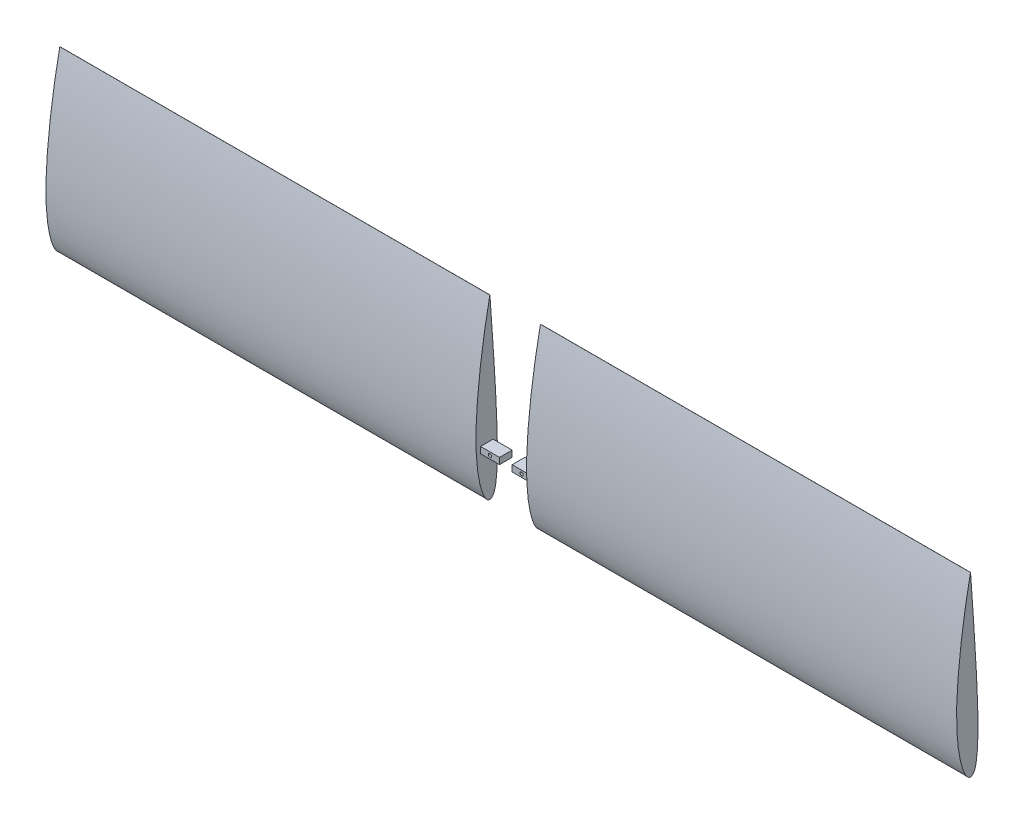
from build123d import *

# Parameters (mm, degrees)
BOSS_EXTRUDE1_DEPTH     = 914.4
SKETCH2_W               = 101.6
SKETCH2_H               = 355.7016
CUT_EXTRUDE1_DEPTH      = 982.547981928
CUT_EXTRUDE1_DEPTH_BACK = 982.547981928
CUT_EXTRUDE3_DEPTH      = 862.965
BOSS_EXTRUDE2_DEPTH     = 862.965
SKETCH7_W               = 25.4
SKETCH7_H               = 12.7
BOSS_EXTRUDE3_DEPTH     = 38.1
SKETCH8_R               = 3.175
CUT_EXTRUDE4_DEPTH      = 982.730874327


with BuildPart() as part:
    # Sketch1 → Boss-Extrude1 (new body)
    with BuildSketch(Plane(origin=(0, 0, 0), x_dir=(0, 0, -1), z_dir=(1, 0, 0))):
        with BuildLine():
            Line((0.107161403, 355.7016), (-0.070689384, 355.7016))
            add(Edge.make_bspline(
                [(-0.070689384, 355.7016), (-0.466477301, 353.821005474), (-1.257390268, 350.062966049), (-2.391261843, 344.419849121), (-3.495815308, 338.780602167), (-4.571931897, 333.145611843), (-5.624146346, 327.516510889), (-6.654132743, 321.894595016), (-7.997398438, 314.419324109), (-9.945522406, 303.25746297), (-12.095688112, 290.277775074), (-14.108266379, 277.369668), (-15.729652448, 266.404083363), (-17.745206313, 251.980108498), (-19.571200264, 237.689627436), (-21.215305741, 223.549431816), (-22.347366905, 213.141900318), (-23.38648148, 202.878012782), (-24.331674295, 192.768060411), (-25.180326784, 182.822187649), (-25.928484577, 173.050367055), (-26.674562593, 161.923020833), (-27.345486328, 149.535714938), (-27.840551721, 135.990974586), (-28.060725611, 122.943312688), (-28.002046095, 110.422427171), (-27.702820577, 99.702001348), (-27.264430386, 90.695171909), (-26.778207129, 83.305058943), (-26.183602895, 76.189184622), (-25.486294476, 69.354718788), (-24.692398131, 62.80853729), (-23.808328586, 56.557201024), (-22.840687769, 50.606973205), (-21.796246166, 44.963830369), (-20.681960011, 39.633415294), (-19.686877519, 35.395642593), (-18.668840846, 31.420703372), (-17.830503911, 28.402995737), (-16.953038009, 25.502253789), (-16.295688834, 23.446152208), (-15.629016033, 21.473655539), (-14.953909817, 19.585256686), (-14.271253624, 17.781420944), (-13.581895135, 16.062595446), (-12.886661884, 14.429199329), (-12.186346807, 12.881628381), (-11.481686051, 11.420261165), (-10.773396292, 10.04543679), (-10.062097884, 8.757490369), (-9.34839284, 7.556709508), (-8.632792002, 6.443369974), (-7.91573903, 5.417716148), (-7.197605959, 4.479967069), (-6.47867767, 3.630320834), (-5.759155979, 2.868957272), (-5.039142048, 2.19605649), (-4.318657554, 1.611798732), (-3.597634906, 1.11641082), (-2.875952573, 0.710164516), (-2.153489626, 0.393485727), (-1.430202503, 0.166619572), (-0.706187065, 0.03077979), (-0.000985808, -0.015114251), (0.684756584, 0.030079625), (1.348697256, 0.166740712), (2.007659563, 0.393317067), (2.659441583, 0.710058446), (3.302103095, 1.116343264), (3.933909812, 1.611857107), (4.553290425, 2.196297771), (5.158827727, 2.869428129), (5.749231153, 3.631048574), (6.323352434, 4.480969847), (6.880184982, 5.418999484), (7.418887755, 6.444929009), (7.938780897, 7.558528262), (8.439333201, 8.759551829), (8.920187899, 10.047719086), (9.38111076, 11.42273555), (9.822040709, 12.884270251), (10.243003979, 14.431978532), (10.644156378, 16.065484925), (11.025729315, 17.78439363), (11.388030769, 19.588284464), (11.731405451, 21.47671562), (12.056228849, 23.449222111), (12.362904642, 25.505314006), (12.65181215, 27.644482252), (12.923317343, 29.866195243), (13.177757541, 32.169900276), (13.499852463, 35.402342989), (13.858312346, 39.644181211), (14.217474108, 44.973851327), (14.512794252, 50.616200438), (14.744290134, 56.565612117), (14.91180091, 62.816123126), (15.015348807, 69.361468336), (15.055556296, 76.19507344), (15.033927365, 83.310049608), (14.95305361, 90.699222818), (14.816566284, 98.355150745), (14.628926379, 106.27014854), (14.395047132, 114.436264929), (14.119797884, 122.845292004), (13.80742065, 131.488784123), (13.461091997, 140.358056449), (13.082513447, 149.444192088), (12.529118258, 161.966906534), (11.914202813, 174.747012914), (11.23057546, 187.771233814), (10.673385511, 197.800288277), (10.076443223, 207.988276057), (9.333666459, 220.087933402), (8.545388829, 232.345213804), (7.727884289, 244.74825108), (7.012410075, 255.522479057), (6.413248687, 264.566087926), (5.812205548, 273.686981089), (5.209897824, 282.876004642), (4.484082626, 293.955761906), (3.867734567, 303.229482659), (3.360161258, 310.676514812), (2.970245095, 316.279904259), (2.570443063, 321.893186998), (2.160539213, 327.514926735), (1.741925541, 333.143678), (1.317712761, 338.777987211), (0.895533142, 344.416460162), (0.48132907, 350.057405862), (0.231880233, 353.820258158), (0.107161403, 355.7016)],
                knots=[0, 0, 0, 0, 0.007940543, 0.015867786, 0.023782336, 0.031683842, 0.039571466, 0.047443805, 0.055299407, 0.070952907, 0.094259966, 0.109659749, 0.124931368, 0.140060475, 0.169836167, 0.184455938, 0.198878988, 0.213091981, 0.227081364, 0.240833733, 0.254335896, 0.267574898, 0.286913018, 0.305591757, 0.323574751, 0.340828862, 0.357323531, 0.367884026, 0.378086462, 0.387923234, 0.397387015, 0.406470797, 0.41516795, 0.423472244, 0.43137777, 0.438879022, 0.445971139, 0.449362331, 0.455832514, 0.458910652, 0.461883669, 0.464751272, 0.467513247, 0.470169459, 0.472719872, 0.475164567, 0.477503762, 0.479737826, 0.481867333, 0.483893084, 0.485816152, 0.487637951, 0.489360303, 0.49098553, 0.492516542, 0.493957004, 0.495311466, 0.496585561, 0.4977862, 0.498921787, 0.500002352, 0.50103964, 0.502046987, 0.503038995, 0.503951731, 0.504878158, 0.505831393, 0.506823576, 0.507865603, 0.508967032, 0.510136107, 0.511379885, 0.512704371, 0.51411466, 0.515615093, 0.517209348, 0.518900571, 0.520691419, 0.522584144, 0.524580638, 0.526682478, 0.528890964, 0.531207133, 0.533631806, 0.536165599, 0.538808937, 0.541562081, 0.544425147, 0.547398108, 0.550480817, 0.553673027, 0.556974385, 0.563902733, 0.571261381, 0.579045037, 0.58724742, 0.595861595, 0.604880098, 0.614294871, 0.624097261, 0.634278056, 0.644827522, 0.655735355, 0.666990799, 0.678582536, 0.690498843, 0.702727789, 0.715257042, 0.728074047, 0.754520377, 0.768123571, 0.781962351, 0.796022904, 0.810291085, 0.832050541, 0.846772874, 0.861649926, 0.876666219, 0.884221743, 0.899417941, 0.914715475, 0.9300999, 0.937820202, 0.945556969, 0.953308312, 0.961072259, 0.968846879, 0.976629764, 0.984418334, 0.992209516, 1, 1, 1, 1], degree=3))
        make_face()
    extrude(amount=-BOSS_EXTRUDE1_DEPTH)

    # Sketch2 → Cut-Extrude1 (cut, two sides)
    with BuildSketch(Plane.XY) as cut_extrude1_sk:
        with Locations((0, 177.8508)):
            Rectangle(SKETCH2_W, SKETCH2_H)
    extrude(amount=CUT_EXTRUDE1_DEPTH, mode=Mode.SUBTRACT)
    extrude(cut_extrude1_sk.sketch, amount=-CUT_EXTRUDE1_DEPTH_BACK, mode=Mode.SUBTRACT)

    # Sketch4 → Cut-Extrude3 (cut)
    with BuildSketch(Plane(origin=(-50.8, 0, 0), x_dir=(0, 0, -1), z_dir=(1, 0, 0))):
        with BuildLine():
            add(Edge.make_bspline(
                [(0.001596468, 0.634990121), (0.826967902, 0.634990121), (2.460288034, 1.127474544), (4.471748408, 2.891385333), (6.048409656, 5.115682959), (7.725860803, 8.396685666), (9.248617399, 12.803937935), (10.558588728, 18.266080522), (11.537271469, 23.813406951), (12.540599127, 31.267756807), (13.390897577, 40.646027038), (14.019287877, 51.93516664), (14.364838797, 63.240945561), (14.494341209, 74.553940311), (14.440507649, 89.641826641), (14.046896931, 108.502916127), (13.28515646, 131.132642203), (12.358459727, 153.75815723), (11.295867035, 176.377547342), (10.08079803, 198.988797347), (8.25161926, 229.125707637), (6.215879665, 259.254310072), (4.246071484, 289.388584475), (2.759176481, 311.986719647), (1.243059906, 332.911934061), (0.185033848, 346.644175304), (-0.240044354, 352.854074493), (-0.262610008, 353.185684255)],
                knots=[0.503016093, 0.503016093, 0.503016093, 0.503016093, 0.50689878, 0.510781467, 0.514664154, 0.51854684, 0.526312214, 0.534077587, 0.541842961, 0.549608335, 0.565139082, 0.580669829, 0.596200576, 0.611731323, 0.62726207, 0.658323564, 0.689385058, 0.720446552, 0.751508047, 0.782569541, 0.813631035, 0.875754023, 0.906815517, 0.937877012, 0.968938506, 0.993166121, 0.994532897, 0.994532897, 0.994532897, 0.994532897], degree=3))
            add(Edge.make_bspline(
                [(-0.262610008, 353.185684255), (-0.330089775, 352.861585336), (-1.613269803, 346.682459156), (-4.285724244, 332.991692094), (-9.434644884, 304.554879268), (-15.494971488, 266.846612876), (-20.283754942, 228.954525342), (-23.392595569, 198.561830787), (-25.324232267, 175.73139216), (-26.762300805, 152.867342407), (-27.558019979, 129.975401306), (-27.529610967, 107.073364668), (-26.655615015, 88.010905167), (-25.329926205, 72.809478404), (-23.982889398, 61.446997862), (-22.232135743, 50.142596476), (-20.002416998, 38.927558947), (-17.650066352, 29.698843837), (-15.364424641, 22.442601279), (-13.400772139, 17.092196396), (-11.113363598, 11.885208097), (-8.833207499, 7.747064384), (-6.64177054, 4.711865499), (-4.133557145, 1.997235658), (-1.717329915, 0.635031043), (0.001596468, 0.634990121)],
                knots=[0.00545209, 0.00545209, 0.00545209, 0.00545209, 0.006815112, 0.031438495, 0.06287699, 0.125753979, 0.188630969, 0.220069464, 0.251507959, 0.282946453, 0.314384948, 0.345823443, 0.377261938, 0.392981185, 0.408700433, 0.42441968, 0.440138928, 0.455858175, 0.463717799, 0.471577422, 0.479437046, 0.48729667, 0.491226482, 0.495156294, 0.503015917, 0.503015917, 0.503015917, 0.503015917], degree=3))
        make_face()
    extrude(amount=-CUT_EXTRUDE3_DEPTH, mode=Mode.SUBTRACT)



with BuildPart() as body_2:
    # Sketch6 → Boss-Extrude2 (new body)
    with BuildSketch(Plane(origin=(-50.8, 0, 0), x_dir=(0, 0, -1), z_dir=(1, 0, 0))):
        with BuildLine():
            add(Edge.make_bspline(
                [(-0.262610008, 353.185684255), (-0.330089775, 352.861585336), (-1.613269803, 346.682459156), (-4.285724244, 332.991692094), (-9.434644884, 304.554879268), (-15.494971488, 266.846612876), (-20.283754942, 228.954525342), (-23.392595569, 198.561830787), (-25.324232267, 175.73139216), (-26.762300805, 152.867342407), (-27.558019979, 129.975401306), (-27.529610967, 107.073364668), (-26.655615015, 88.010905167), (-25.329926205, 72.809478404), (-23.982889398, 61.446997862), (-22.232135743, 50.142596476), (-20.002416998, 38.927558947), (-17.650066352, 29.698843837), (-15.364424641, 22.442601279), (-13.400772139, 17.092196396), (-11.113363598, 11.885208097), (-8.833207499, 7.747064384), (-6.64177054, 4.711865499), (-4.133557145, 1.997235658), (-1.717329915, 0.635031043), (0.001596468, 0.634990121)],
                knots=[0.00545209, 0.00545209, 0.00545209, 0.00545209, 0.006815112, 0.031438495, 0.06287699, 0.125753979, 0.188630969, 0.220069464, 0.251507959, 0.282946453, 0.314384948, 0.345823443, 0.377261938, 0.392981185, 0.408700433, 0.42441968, 0.440138928, 0.455858175, 0.463717799, 0.471577422, 0.479437046, 0.48729667, 0.491226482, 0.495156294, 0.503015917, 0.503015917, 0.503015917, 0.503015917], degree=3))
            add(Edge.make_bspline(
                [(0.001596468, 0.634990121), (0.826967902, 0.634990121), (2.460288034, 1.127474544), (4.471748408, 2.891385333), (6.048409656, 5.115682959), (7.725860803, 8.396685666), (9.248617399, 12.803937935), (10.558588728, 18.266080522), (11.537271469, 23.813406951), (12.540599127, 31.267756807), (13.390897577, 40.646027038), (14.019287877, 51.93516664), (14.364838797, 63.240945561), (14.494341209, 74.553940311), (14.440507649, 89.641826641), (14.046896931, 108.502916127), (13.28515646, 131.132642203), (12.358459727, 153.75815723), (11.295867035, 176.377547342), (10.08079803, 198.988797347), (8.25161926, 229.125707637), (6.215879665, 259.254310072), (4.246071484, 289.388584475), (2.759176481, 311.986719647), (1.243059906, 332.911934061), (0.185033848, 346.644175304), (-0.240044354, 352.854074493), (-0.262610008, 353.185684255)],
                knots=[0.503016093, 0.503016093, 0.503016093, 0.503016093, 0.50689878, 0.510781467, 0.514664154, 0.51854684, 0.526312214, 0.534077587, 0.541842961, 0.549608335, 0.565139082, 0.580669829, 0.596200576, 0.611731323, 0.62726207, 0.658323564, 0.689385058, 0.720446552, 0.751508047, 0.782569541, 0.813631035, 0.875754023, 0.906815517, 0.937877012, 0.968938506, 0.993166121, 0.994532897, 0.994532897, 0.994532897, 0.994532897], degree=3))
        make_face()
    extrude(amount=-BOSS_EXTRUDE2_DEPTH)


with BuildPart() as part_1:
    add(part.part)

    add(body_2.part)  # Boss-Extrude3 merges body 2
    # Sketch7 → Boss-Extrude3 (add)
    with BuildSketch(Plane(origin=(-50.8, 0, 0), x_dir=(0, 0, -1), z_dir=(1, 0, 0))):
        with Locations((-6.084827814, 95.2754)):
            Rectangle(SKETCH7_W, SKETCH7_H)
    extrude(amount=BOSS_EXTRUDE3_DEPTH)

    # Sketch8 → Cut-Extrude4 (cut, through all)
    with BuildSketch(Plane.XY.offset(18.784827814)):
        with Locations((-31.75, 95.2754)):
            Circle(SKETCH8_R)
    extrude(amount=-CUT_EXTRUDE4_DEPTH, mode=Mode.SUBTRACT)


with BuildPart() as body_2_2:
    # Mirror2: mirrored copy
    add(part_1.part.mirror(Plane(origin=(0, 0, 0), x_dir=(0, 0, 1), z_dir=(1, 0, 0))))


solid = Compound([part_1.part, body_2_2.part])
